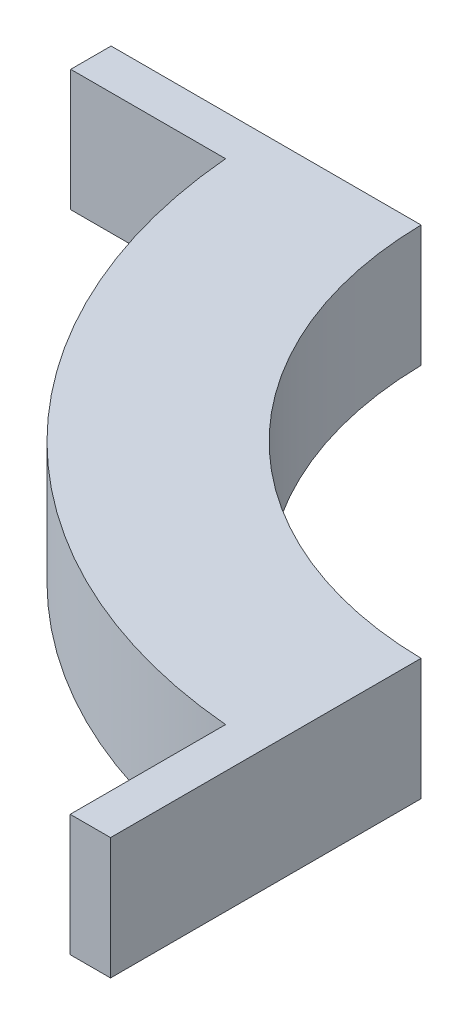
from build123d import *

# Parameters (mm, degrees)
BOSS_EXTRUDE1_DEPTH = 50.8


with BuildPart() as part:
    # Sketch2 → Boss-Extrude1 (new body)
    with BuildSketch(Plane(origin=(0, 0, 0), x_dir=(1, 0, 0), z_dir=(0, 1, 0))):
        with BuildLine():
            Line((-288.815722864, -19.398264696), (-224.124430379, -19.398264696))
            ThreePointArc((-224.124430379, -19.398264696), (-159.072393843, -159.072393843), (-19.398264696, -224.124430379))
            Line((-19.398264696, -224.124430379), (-19.398264696, -289.040694823))
            Line((-19.398264696, -289.040694823), (-2.54, -289.040694823))
            Line((-2.54, -289.040694823), (-2.54, -159.324855717))
            ThreePointArc((-2.54, -159.324855717), (-112.674001547, -112.674001547), (-159.324855717, -2.54))
            Line((-159.324855717, -2.54), (-288.815722864, -2.54))
            Line((-288.815722864, -2.54), (-288.815722864, -19.398264696))
        make_face()
    extrude(amount=BOSS_EXTRUDE1_DEPTH)


solid = part.part
